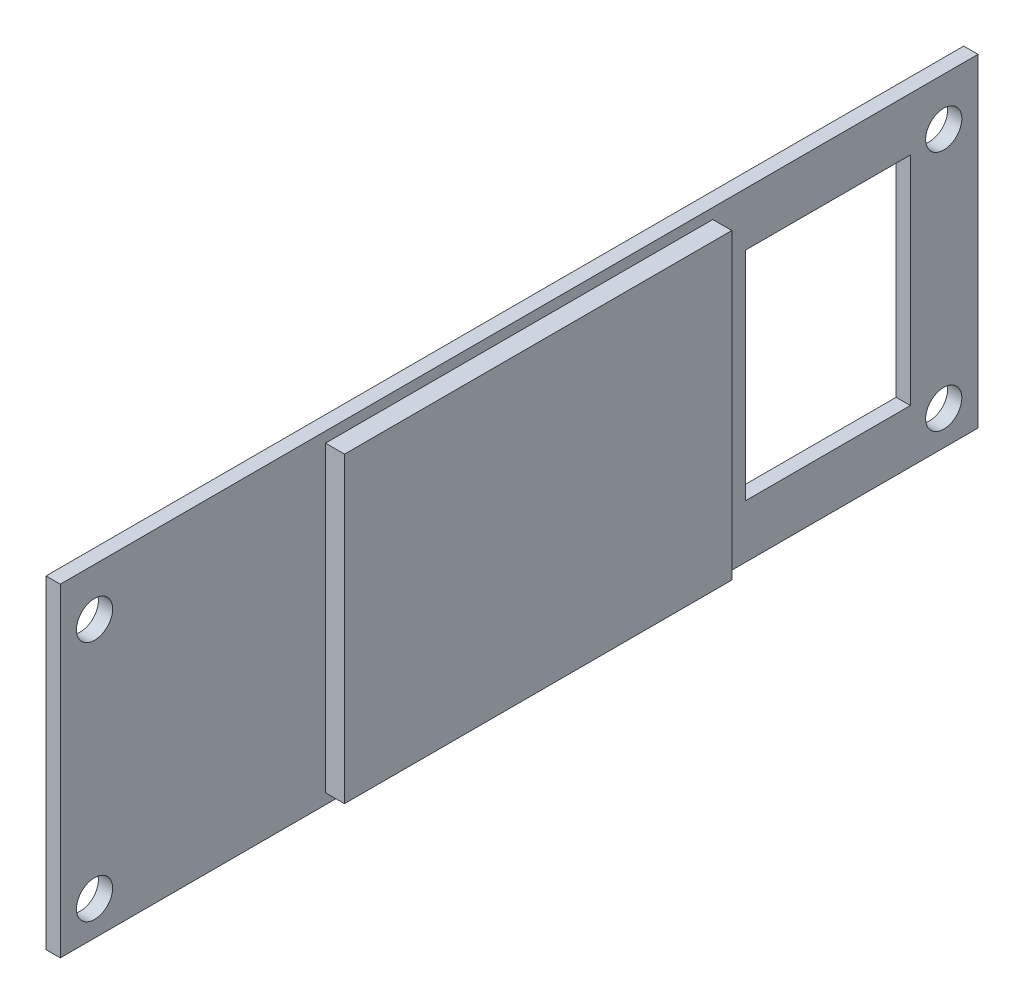
from build123d import *

# Parameters (mm, degrees)
SKETCH1_W           = 122.428
SKETCH1_H           = 43.18
BOSS_EXTRUDE1_DEPTH = 1.905
SKETCH2_R           = 2.413
CUT_EXTRUDE1_DEPTH  = 1.905
CUT_EXTRUDE2_DEPTH  = 1.905
SKETCH4_W           = 21.971
SKETCH4_H           = 28.956
CUT_EXTRUDE3_DEPTH  = 1.905
SKETCH5_W           = 51.6678832
SKETCH5_H           = 40.386705486
BOSS_EXTRUDE2_DEPTH = 2.54


with BuildPart() as part:
    # Sketch1 → Boss-Extrude1 (new body)
    with BuildSketch(Plane(origin=(0, 0, 0), x_dir=(0, 0, -1), z_dir=(1, 0, 0))):
        Rectangle(SKETCH1_W, SKETCH1_H)
    extrude(amount=-BOSS_EXTRUDE1_DEPTH)

    # Sketch2 → Cut-Extrude1 (cut)
    with BuildSketch(Plane(origin=(0, 0, 0), x_dir=(0, 0, -1), z_dir=(1, 0, 0))):
        with Locations((-56.642, 15.24)):
            Circle(SKETCH2_R)
        with Locations((-56.642, -17.018)):
            Circle(SKETCH2_R)
        with Locations((56.642, 15.24)):
            Circle(SKETCH2_R)
        with Locations((56.642, -17.018)):
            Circle(SKETCH2_R)
    extrude(amount=-CUT_EXTRUDE1_DEPTH, mode=Mode.SUBTRACT)

    # Sketch3 → Cut-Extrude2 (cut)
    with BuildSketch(Plane(origin=(0, 0, 0), x_dir=(0, 0, -1), z_dir=(1, 0, 0))):
        with BuildLine():
            ThreePointArc((-10.636223834, -15.804215974), (0, -19.05), (10.636223834, -15.804215974))
            ThreePointArc((10.636223834, -15.804215974), (12.123345763, -12.123345763), (15.804215974, -10.636223834))
            ThreePointArc((15.804215974, -10.636223834), (19.05, 0), (15.804215974, 10.636223834))
            ThreePointArc((15.804215974, 10.636223834), (12.123345763, 12.123345763), (10.636223834, 15.804215974))
            ThreePointArc((10.636223834, 15.804215974), (0, 19.05), (-10.636223834, 15.804215974))
            ThreePointArc((-10.636223834, 15.804215974), (-12.123345763, 12.123345763), (-15.804215974, 10.636223834))
            ThreePointArc((-15.804215974, 10.636223834), (-19.05, 0), (-15.804215974, -10.636223834))
            ThreePointArc((-15.804215974, -10.636223834), (-12.123345763, -12.123345763), (-10.636223834, -15.804215974))
        make_face()
    extrude(amount=-CUT_EXTRUDE2_DEPTH, mode=Mode.SUBTRACT)

    # Sketch4 → Cut-Extrude3 (cut)
    with BuildSketch(Plane.ZY.offset(1.905)):
        with Locations((-41.2115, 0)):
            Rectangle(SKETCH4_W, SKETCH4_H)
    extrude(amount=-CUT_EXTRUDE3_DEPTH, mode=Mode.SUBTRACT)

    # Sketch5 → Boss-Extrude2 (add)
    with BuildSketch(Plane(origin=(0, 0, 0), x_dir=(0, 0, -1), z_dir=(1, 0, 0))):
        Rectangle(SKETCH5_W, SKETCH5_H)
    extrude(amount=BOSS_EXTRUDE2_DEPTH)


solid = part.part
